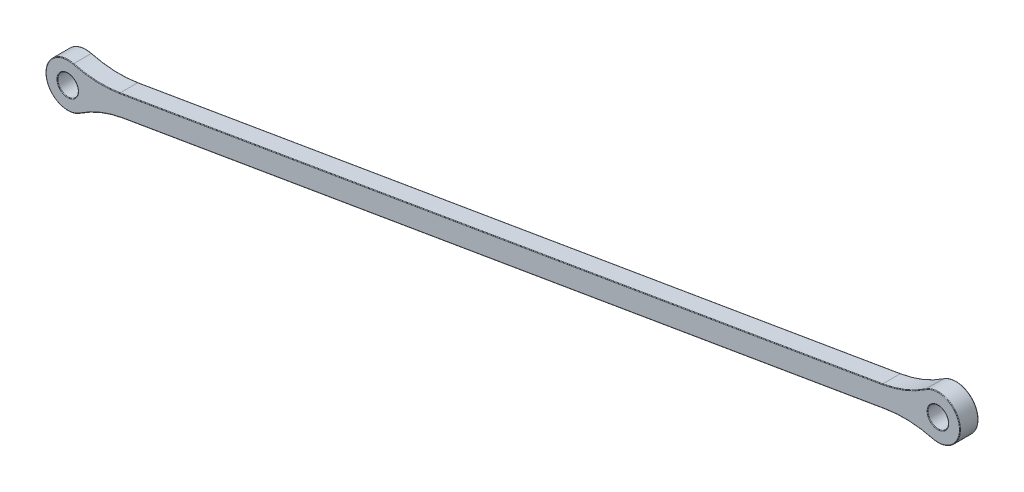
from build123d import *

# Parameters (mm, degrees)
BOSS_EXTRUDE1_DEPTH = 5
FILLET1_R           = 30
FILLET2_R           = 0.15


with BuildPart() as part:
    # Sketch1 → Boss-Extrude1 (new body)
    with BuildSketch(Plane.XY):
        with BuildLine():
            ThreePointArc((-307.508268688, 260.337372781), (-310.736888168, 262.629973107), (-308.444287841, 265.858592586))
            Line((-308.444287841, 265.858592586), (-303.212340846, 266.745570965))
            ThreePointArc((-303.212340846, 266.745570965), (-313.891870914, 262.09510502), (-302.276321694, 261.22435116))
            Line((-302.276321694, 261.22435116), (-307.508268688, 260.337372781))
        make_face()
        with BuildLine():
            Line((-303.212340846, 266.745570965), (-308.444287841, 265.858592586))
            ThreePointArc((-308.444287841, 265.858592586), (-305.215668362, 263.56599226), (-307.508268688, 260.337372781))
            Line((-307.508268688, 260.337372781), (-302.276321694, 261.22435116))
            ThreePointArc((-302.276321694, 261.22435116), (-302.051763963, 262.149230721), (-301.976278265, 263.097982683))
            ThreePointArc((-301.976278265, 263.097982683), (-302.293689748, 265.023648217), (-303.212340846, 266.745570965))
        make_face()
        with BuildLine():
            ThreePointArc((-65.352572296, 303.213089234), (-70.403820333, 309.137603536), (-77.052528867, 305.086720758))
            Line((-77.052528867, 305.086720758), (-71.820581872, 305.973699137))
            ThreePointArc((-71.820581872, 305.973699137), (-68.591962393, 303.68109881), (-70.884562719, 300.452479331))
            Line((-70.884562719, 300.452479331), (-76.116509714, 299.565500952))
            ThreePointArc((-76.116509714, 299.565500952), (-69.426906763, 297.530500717), (-65.352572296, 303.213089234))
        make_face()
        with BuildLine():
            Line((-71.820581872, 305.973699137), (-77.052528867, 305.086720758))
            ThreePointArc((-77.052528867, 305.086720758), (-77.268164945, 302.21021157), (-76.116509714, 299.565500952))
            Line((-76.116509714, 299.565500952), (-70.884562719, 300.452479331))
            ThreePointArc((-70.884562719, 300.452479331), (-74.113182199, 302.745079658), (-71.820581872, 305.973699137))
        make_face()
        with BuildLine():
            Line((-77.052528867, 305.086720758), (-303.212340846, 266.745570965))
            ThreePointArc((-303.212340846, 266.745570965), (-302.293689748, 265.023648217), (-301.976278265, 263.097982683))
            ThreePointArc((-301.976278265, 263.097982683), (-302.051763963, 262.149230721), (-302.276321694, 261.22435116))
            Line((-302.276321694, 261.22435116), (-76.116509714, 299.565500952))
            ThreePointArc((-76.116509714, 299.565500952), (-77.268164945, 302.21021157), (-77.052528867, 305.086720758))
        make_face()
    extrude(amount=-BOSS_EXTRUDE1_DEPTH)

    # Fillet1
    fillet1_edges = [part.edges().sort_by_distance(p)[0] for p in [
        (-303.212340846, 266.745570965, -2.5),
        (-77.052528867, 305.086720758, -2.5),
        (-76.116509714, 299.565500952, -2.5),
        (-302.276321694, 261.22435116, -2.5),
    ]]
    fillet(fillet1_edges, radius=FILLET1_R)

    # Fillet2
    fillet2_edges = [part.edges().sort_by_distance(p)[0] for p in [
        (-71.820581872, 305.973699137, 0),
        (-313.891870914, 262.09510502, 0),
        (-313.891870914, 262.09510502, -5),
        (-189.196415704, 280.394926056, 0),
        (-189.196415704, 280.394926056, -5),
        (-65.436979647, 304.215966898, 0),
        (-65.436979647, 304.215966898, -5),
        (-190.132434857, 285.916145862, 0),
        (-190.132434857, 285.916145862, -5),
        (-299.0021004, 261.095569977, 0),
        (-299.0021004, 261.095569977, -5),
        (-79.165336458, 298.364765695, 0),
        (-308.444287841, 265.858592586, -5),
        (-79.165336458, 298.364765695, -5),
        (-80.326750161, 305.21550194, 0),
        (-80.326750161, 305.21550194, -5),
        (-300.163514102, 267.946306222, 0),
        (-300.163514102, 267.946306222, -5),
        (-71.820581872, 305.973699137, -5),
        (-308.444287841, 265.858592586, 0),
    ]]
    fillet(fillet2_edges, radius=FILLET2_R)


solid = part.part
